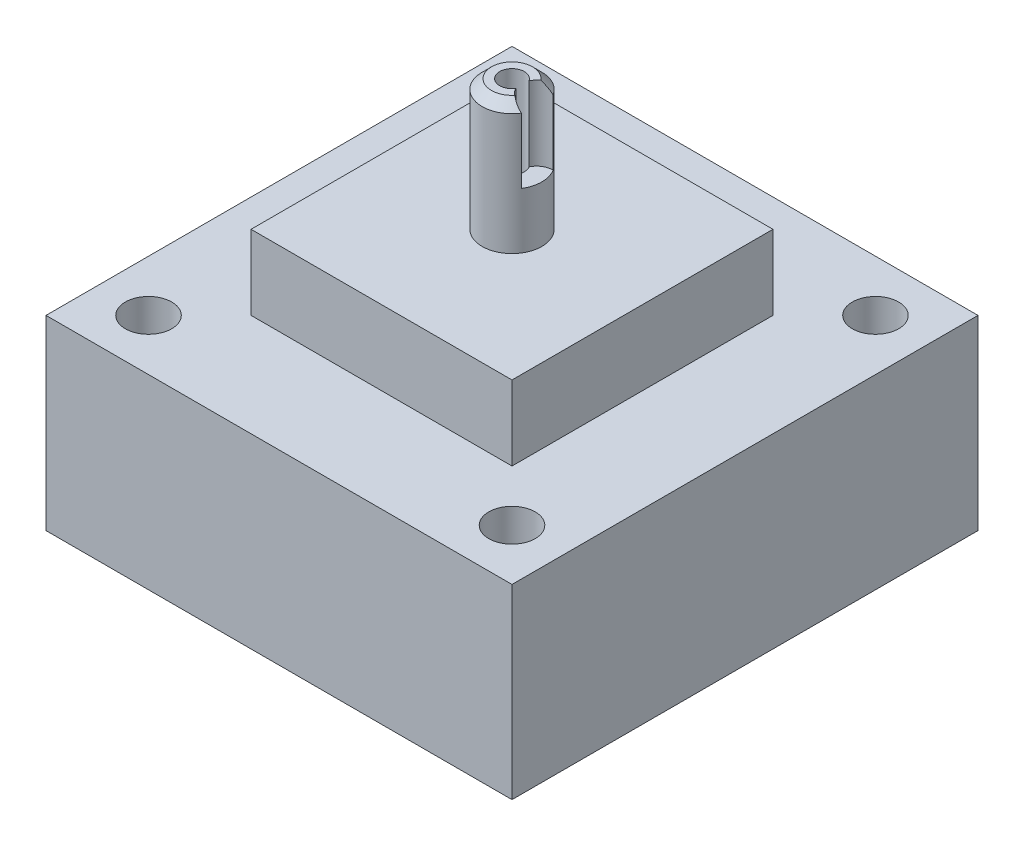
from build123d import *

# Parameters (mm, degrees)
SKETCH1_W           = 14
SKETCH1_H           = 14
BOSS_EXTRUDE1_DEPTH = 4
SKETCH2_W           = 25
SKETCH2_H           = 25
SKETCH2_R           = 1.2446
BOSS_EXTRUDE2_DEPTH = 10
SKETCH3_R           = 4.23
CUT_EXTRUDE1_DEPTH  = 9.8
SKETCH5_R           = 0.6604
CUT_EXTRUDE2_DEPTH  = 14
SKETCH8_R           = 0.85
CUT_EXTRUDE3_DEPTH  = 4


with BuildPart() as part:
    # Sketch1 → Boss-Extrude1 (new body)
    with BuildSketch(Plane(origin=(0, 0, 0), x_dir=(1, 0, 0), z_dir=(0, 1, 0))):
        Rectangle(SKETCH1_W, SKETCH1_H)
    extrude(amount=BOSS_EXTRUDE1_DEPTH)

    # Sketch2 → Boss-Extrude2 (add)
    with BuildSketch(Plane.XZ):
        Rectangle(SKETCH2_W, SKETCH2_H)
        with Locations((-9.75, 9.75)):
            Circle(SKETCH2_R, mode=Mode.SUBTRACT)
        with Locations((9.75, 9.75)):
            Circle(SKETCH2_R, mode=Mode.SUBTRACT)
        with Locations((9.75, -9.75)):
            Circle(SKETCH2_R, mode=Mode.SUBTRACT)
        with Locations((-9.75, -9.75)):
            Circle(SKETCH2_R, mode=Mode.SUBTRACT)
    extrude(amount=BOSS_EXTRUDE2_DEPTH)

    # Sketch3 → Cut-Extrude1 (cut)
    with BuildSketch(Plane.XZ.offset(10)):
        Circle(SKETCH3_R)
    extrude(amount=-CUT_EXTRUDE1_DEPTH, mode=Mode.SUBTRACT)

    # Sketch4 → Revolve1 (revolve)
    with BuildSketch(Plane(origin=(0, 0, 0), x_dir=(0, 0, -1), z_dir=(1, 0, 0))):
        Polygon((0.6604, 11), (0.6604, 4), (1.6, 4), (1.6, 10.5), (1.1, 11), align=None)
    revolve(axis=Axis((0, 4, 0), (0, 1, 0)))

    # Sketch5 → Cut-Extrude2 (cut)
    with BuildSketch(Plane(origin=(0, 4, 0), x_dir=(1, 0, 0), z_dir=(0, 1, 0))):
        Circle(SKETCH5_R)
    extrude(amount=-CUT_EXTRUDE2_DEPTH, mode=Mode.SUBTRACT)

    # Sketch8 → Cut-Extrude3 (cut)
    with BuildSketch(Plane(origin=(0, 11, 0), x_dir=(1, 0, 0), z_dir=(0, 1, 0))):
        with Locations((1.334621812, 0)):
            Circle(SKETCH8_R)
    extrude(amount=-CUT_EXTRUDE3_DEPTH, mode=Mode.SUBTRACT)


solid = part.part
